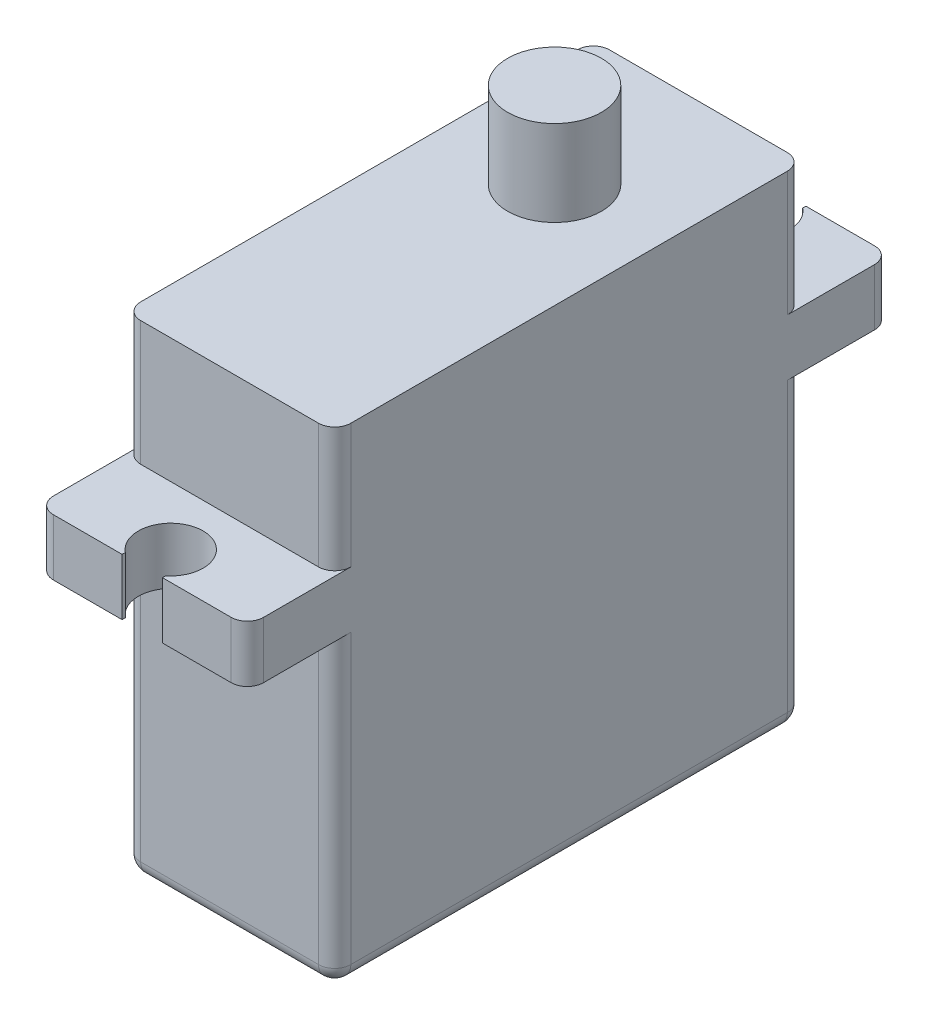
from build123d import *

# Parameters (mm, degrees)
SKETCH2_W           = 29
SKETCH2_H           = 30
SKETCH2_W_2         = 5.4
SKETCH2_H_2         = 3.5
SKETCH2_W_3         = 5.8
SKETCH2_H_3         = 5.3
BOSS_EXTRUDE1_DEPTH = 13
CUT_EXTRUDE1_DEPTH  = 5.3
CUT_EXTRUDE2_DEPTH  = 31
FILLET1_R           = 1


with BuildPart() as part:
    # Sketch2 → Boss-Extrude1 (new body)
    with BuildSketch(Plane(origin=(0, 0, 0), x_dir=(0, 0, -1), z_dir=(1, 0, 0))):
        Rectangle(SKETCH2_W, SKETCH2_H)
        with Locations((-17.2, 5.55)):
            Rectangle(SKETCH2_W_2, SKETCH2_H_2)
        with Locations((5.6, 17.65)):
            Rectangle(SKETCH2_W_3, SKETCH2_H_3)
        with Locations((17.2, 5.55)):
            Rectangle(SKETCH2_W_2, SKETCH2_H_2)
    extrude(amount=BOSS_EXTRUDE1_DEPTH)

    # Sketch3 → Cut-Extrude1 (cut)
    with BuildSketch(Plane(origin=(0, 15, 0), x_dir=(1, 0, 0), z_dir=(0, 1, 0))):
        with BuildLine():
            Line((6.5, 2.7), (9.4, 2.7))
            Line((9.4, 2.7), (9.4, 5.6))
            ThreePointArc((9.4, 5.6), (8.550609665, 3.549390335), (6.5, 2.7))
        make_face()
        with BuildLine():
            ThreePointArc((6.5, 8.5), (8.550609665, 7.650609665), (9.4, 5.6))
            Line((9.4, 5.6), (9.4, 8.5))
            Line((9.4, 8.5), (6.5, 8.5))
        make_face()
        with BuildLine():
            ThreePointArc((3.6, 5.6), (4.449390335, 7.650609665), (6.5, 8.5))
            Line((6.5, 8.5), (3.6, 8.5))
            Line((3.6, 8.5), (3.6, 5.6))
        make_face()
        with BuildLine():
            Line((3.6, 2.7), (6.5, 2.7))
            ThreePointArc((6.5, 2.7), (4.449390335, 3.549390335), (3.6, 5.6))
            Line((3.6, 5.6), (3.6, 2.7))
        make_face()
        Polygon((0, 2.7), (3.6, 2.7), (3.6, 5.6), (3.6, 8.5), (0, 8.5), align=None)
        Polygon((9.4, 2.7), (13, 2.7), (13, 8.5), (9.4, 8.5), (9.4, 5.6), align=None)
        with BuildLine():
            Line((7.75, 19.7), (7.75, 19.9))
            Line((7.75, 19.9), (5.25, 19.9))
            Line((5.25, 19.9), (5.25, 19.7))
            ThreePointArc((5.25, 19.7), (6.5, 16.1387505), (7.75, 19.7))
        make_face()
        with BuildLine():
            Line((5.25, -19.9), (7.75, -19.9))
            Line((7.75, -19.9), (7.75, -19.7))
            ThreePointArc((7.75, -19.7), (6.5, -16.1387505), (5.25, -19.7))
            Line((5.25, -19.7), (5.25, -19.9))
        make_face()
    extrude(amount=CUT_EXTRUDE1_DEPTH, mode=Mode.SUBTRACT)

    # Sketch3_4 → Cut-Extrude2 (cut, through all)
    with BuildSketch(Plane(origin=(0, 15, 0), x_dir=(1, 0, 0), z_dir=(0, 1, 0))):
        with BuildLine():
            Line((7.75, 19.7), (7.75, 19.9))
            Line((7.75, 19.9), (5.25, 19.9))
            Line((5.25, 19.9), (5.25, 19.7))
            ThreePointArc((5.25, 19.7), (6.5, 16.1387505), (7.75, 19.7))
        make_face()
        with BuildLine():
            Line((5.25, -19.9), (7.75, -19.9))
            Line((7.75, -19.9), (7.75, -19.7))
            ThreePointArc((7.75, -19.7), (6.5, -16.1387505), (5.25, -19.7))
            Line((5.25, -19.7), (5.25, -19.9))
        make_face()
    extrude(amount=-CUT_EXTRUDE2_DEPTH, mode=Mode.SUBTRACT)

    # Fillet1
    fillet1_edges = [part.edges().sort_by_distance(p)[0] for p in [
        (0, 5.55, -19.9),
        (0, -5.6, -14.5),
        (0, -15, 0),
        (0, -5.6, 14.5),
        (0, 5.55, 19.9),
        (0, 11.15, 14.5),
        (0, 11.15, -14.5),
        (6.5, -15, -14.5),
        (6.5, -15, 14.5),
        (13, 11.15, 14.5),
        (13, 5.55, 19.9),
        (13, 11.15, -14.5),
        (13, -5.6, 14.5),
        (13, -15, 0),
        (13, -5.6, -14.5),
        (13, 5.55, -19.9),
    ]]
    fillet(fillet1_edges, radius=FILLET1_R)


solid = part.part
